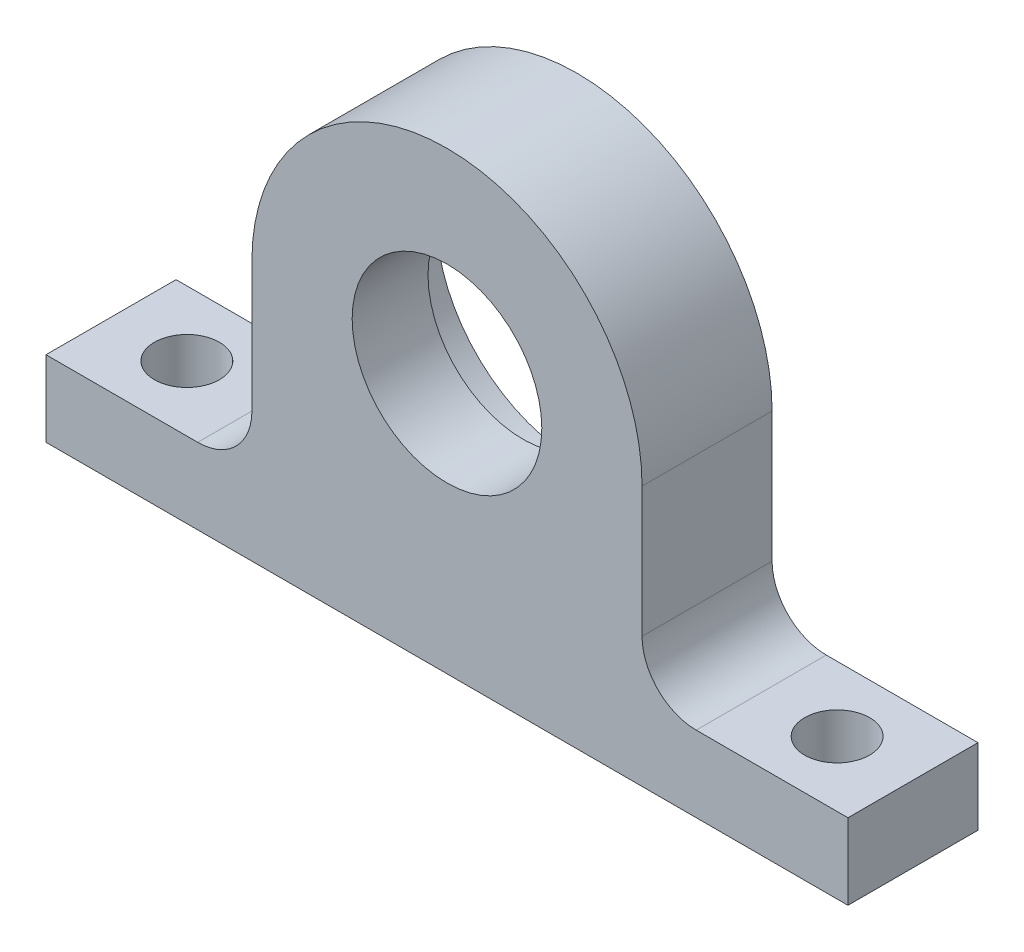
from build123d import *

# Parameters (mm, degrees)
SKETCH1_R           = 8.75
BOSS_EXTRUDE1_DEPTH = 12
SKETCH2_R           = 3
CUT_EXTRUDE1_DEPTH  = 8
SKETCH3_R           = 13
CUT_EXTRUDE2_DEPTH  = 5
BOSS_EXTRUDE2_DEPTH = 12
FILLET2_R           = 5


with BuildPart() as part:
    # Sketch1 → Boss-Extrude1 (new body)
    with BuildSketch(Plane.XY):
        with BuildLine():
            Line((-5.916079783, -17), (-37, -17))
            Line((-37, -17), (-37, -24))
            Line((-37, -24), (0, -24))
            Line((0, -24), (37, -24))
            Line((37, -24), (37, -17))
            Line((37, -17), (5.916079783, -17))
            ThreePointArc((5.916079783, -17), (0, 18), (-5.916079783, -17))
        make_face()
        Circle(SKETCH1_R, mode=Mode.SUBTRACT)
    extrude(amount=BOSS_EXTRUDE1_DEPTH)

    # Sketch2 → Cut-Extrude1 (cut, through all)
    with BuildSketch(Plane(origin=(0, -17, 0), x_dir=(1, 0, 0), z_dir=(0, 1, 0))):
        with Locations((30, -6)):
            Circle(SKETCH2_R)
        with Locations((-30, -6)):
            Circle(SKETCH2_R)
    extrude(amount=-CUT_EXTRUDE1_DEPTH, mode=Mode.SUBTRACT)

    # Sketch3 → Cut-Extrude2 (cut)
    with BuildSketch(Plane(origin=(0, 0, 0), x_dir=(-1, 0, 0), z_dir=(0, 0, -1))):
        Circle(SKETCH3_R)
    extrude(amount=-CUT_EXTRUDE2_DEPTH, mode=Mode.SUBTRACT)

    # Sketch4 → Boss-Extrude2 (add, through all)
    with BuildSketch(Plane(origin=(0, 0, 0), x_dir=(-1, 0, 0), z_dir=(0, 0, -1))):
        Polygon((-18, 0), (-5.916079783, -17), (-18, -17), align=None)
        Polygon((18, 0), (18, -17), (5.916079783, -17), align=None)
    extrude(amount=-BOSS_EXTRUDE2_DEPTH)

    # Fillet2
    fillet2_edges = [part.edges().sort_by_distance(p)[0] for p in [
        (-18, -17, 6),
        (18, -17, 6),
    ]]
    fillet(fillet2_edges, radius=FILLET2_R)


solid = part.part
